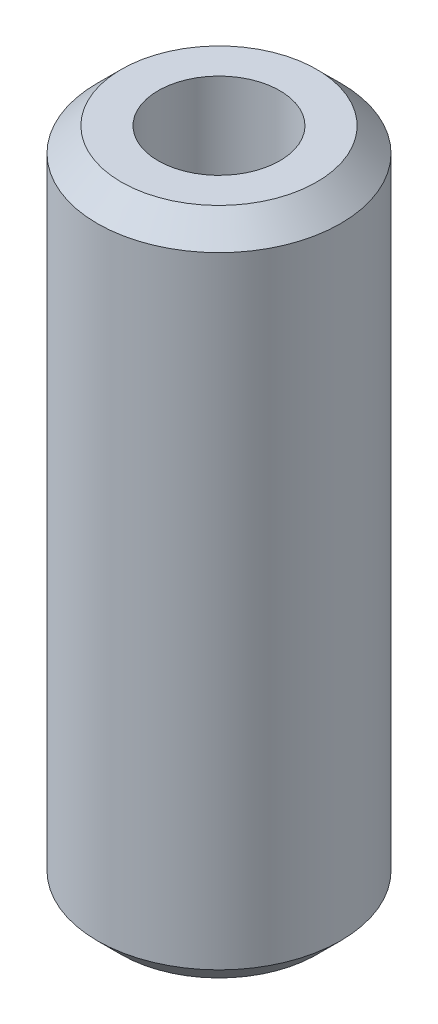
from build123d import *

# Parameters (mm, degrees)
CROQUIS2_R              = 12.7
CROQUIS2_R_2            = 6.35
SALIENTE_EXTRUIR1_DEPTH = 34.925
CHAFL_N1_SIZE           = 2.5


with BuildPart() as part:
    # Croquis2 → Saliente-Extruir1 (new body, symmetric)
    with BuildSketch(Plane(origin=(0, 0, 0), x_dir=(1, 0, 0), z_dir=(0, 1, 0))):
        Circle(CROQUIS2_R)
        Circle(CROQUIS2_R_2, mode=Mode.SUBTRACT)
    extrude(amount=SALIENTE_EXTRUIR1_DEPTH, both=True)

    # Chaflán1
    chafl_n1_edges = [part.edges().sort_by_distance(p)[0] for p in [
        (-12.7, -34.925, 0),
        (-12.7, 34.925, 0),
    ]]
    chamfer(chafl_n1_edges, length=CHAFL_N1_SIZE)


solid = part.part
